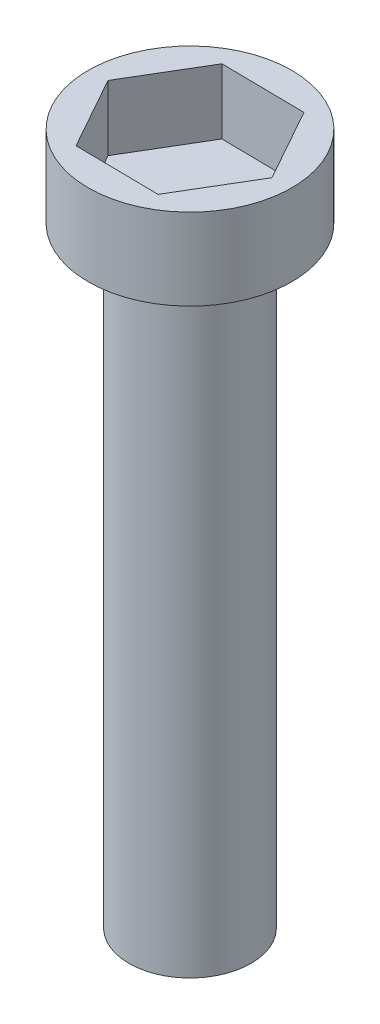
from build123d import *

# Parameters (mm, degrees)
SKETCH1_R           = 1.5
BOSS_EXTRUDE1_DEPTH = 15
SKETCH2_R           = 2.5
BOSS_EXTRUDE2_DEPTH = 2
CUT_EXTRUDE2_DEPTH  = 1.6


with BuildPart() as part:
    # Sketch1 → Boss-Extrude1 (new body)
    with BuildSketch(Plane(origin=(0, 0, 0), x_dir=(1, 0, 0), z_dir=(0, 1, 0))):
        Circle(SKETCH1_R)
    extrude(amount=BOSS_EXTRUDE1_DEPTH)

    # Sketch2 → Boss-Extrude2 (add)
    with BuildSketch(Plane(origin=(0, 15, 0), x_dir=(1, 0, 0), z_dir=(0, 1, 0))):
        Circle(SKETCH2_R)
    extrude(amount=BOSS_EXTRUDE2_DEPTH)

    # Sketch3 → Cut-Extrude2 (cut)
    with BuildSketch(Plane(origin=(0, 17, 0), x_dir=(1, 0, 0), z_dir=(0, 1, 0))):
        Polygon((0.997116077, -1.781560543), (2.041434727, -0.027252418), (1.04431865, 1.754308125), (-0.997116077, 1.781560543), (-2.041434727, 0.027252418), (-1.04431865, -1.754308125), align=None)
    extrude(amount=-CUT_EXTRUDE2_DEPTH, mode=Mode.SUBTRACT)


solid = part.part
